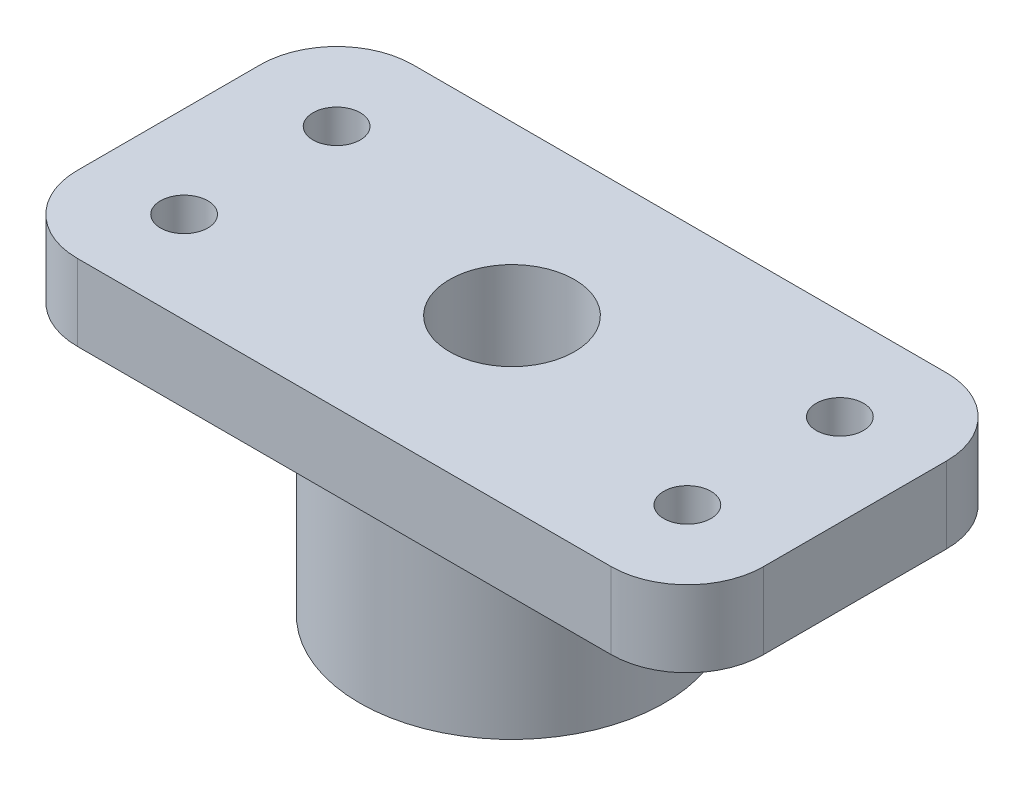
from build123d import *

# Parameters (mm, degrees)
CROQUIS1_R              = 10
CROQUIS1_R_2            = 3.5
EXTRUIR1_DEPTH          = 12
CROQUIS2_W              = 45
CROQUIS2_H              = 22
SALIENTE_EXTRUIR1_DEPTH = 5
REDONDEO1_R             = 5
REDONDEO2_R             = 5
REDONDEO3_R             = 5
REDONDEO4_R             = 5
CROQUIS3_R              = 4.1
CORTAR_EXTRUIR1_DEPTH   = 45
CROQUIS4_R              = 1.55
CORTAR_EXTRUIR2_DEPTH   = 45


with BuildPart() as part:
    # Croquis1 → Extruir1 (new body)
    with BuildSketch(Plane(origin=(0, 0, 0), x_dir=(1, 0, 0), z_dir=(0, 1, 0))):
        Circle(CROQUIS1_R)
        Circle(CROQUIS1_R_2, mode=Mode.SUBTRACT)
    extrude(amount=EXTRUIR1_DEPTH)

    # Croquis2 → Saliente-Extruir1 (add)
    with BuildSketch(Plane(origin=(0, 12, 0), x_dir=(1, 0, 0), z_dir=(0, 1, 0))):
        Rectangle(CROQUIS2_W, CROQUIS2_H)
    extrude(amount=SALIENTE_EXTRUIR1_DEPTH)

    # Redondeo1
    redondeo1_edges = [part.edges().sort_by_distance(p)[0] for p in [
        (22.5, 14.5, -11),
    ]]
    fillet(redondeo1_edges, radius=REDONDEO1_R)

    # Redondeo2
    redondeo2_edges = [part.edges().sort_by_distance(p)[0] for p in [
        (22.5, 14.5, 11),
    ]]
    fillet(redondeo2_edges, radius=REDONDEO2_R)

    # Redondeo3
    redondeo3_edges = [part.edges().sort_by_distance(p)[0] for p in [
        (-22.5, 14.5, 11),
    ]]
    fillet(redondeo3_edges, radius=REDONDEO3_R)

    # Redondeo4
    redondeo4_edges = [part.edges().sort_by_distance(p)[0] for p in [
        (-22.5, 14.5, -11),
    ]]
    fillet(redondeo4_edges, radius=REDONDEO4_R)

    # Croquis3 → Cortar-Extruir1 (cut)
    with BuildSketch(Plane.XZ):
        Circle(CROQUIS3_R)
    extrude(amount=-CORTAR_EXTRUIR1_DEPTH, mode=Mode.SUBTRACT)

    # Croquis4 → Cortar-Extruir2 (cut)
    with BuildSketch(Plane.XZ.offset(-12)):
        with Locations((-16.5, 5)):
            Circle(CROQUIS4_R)
        with Locations((-16.5, -5)):
            Circle(CROQUIS4_R)
        with Locations((16.5, 5)):
            Circle(CROQUIS4_R)
        with Locations((16.5, -5)):
            Circle(CROQUIS4_R)
    extrude(amount=-CORTAR_EXTRUIR2_DEPTH, mode=Mode.SUBTRACT)


solid = part.part
